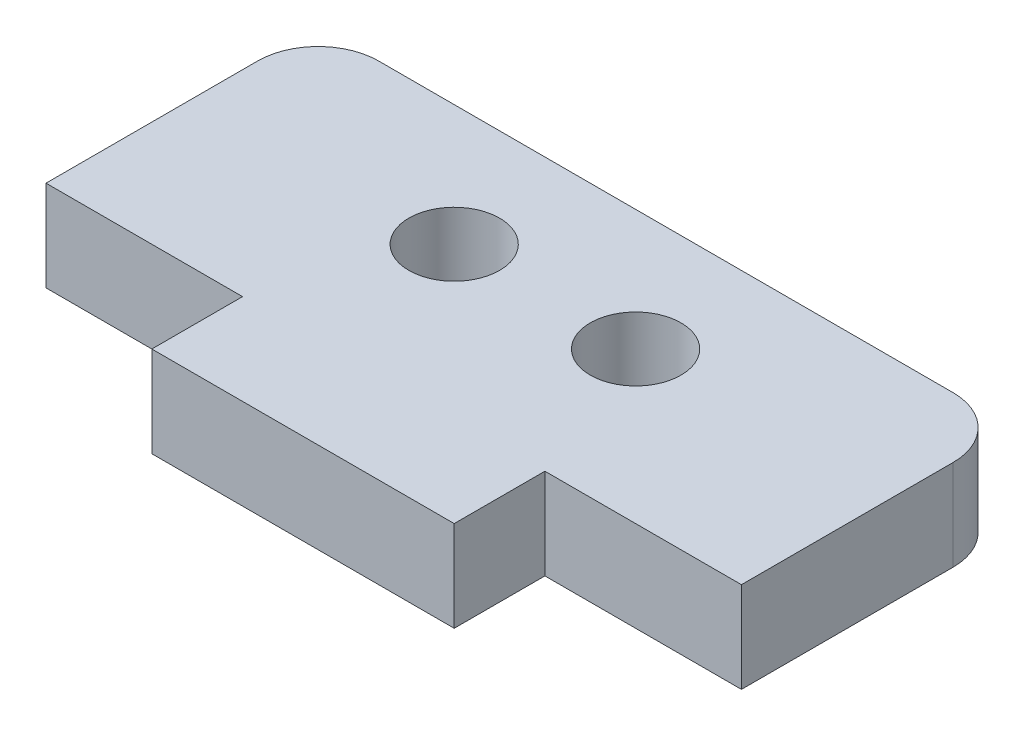
from build123d import *

# Parameters (mm, degrees)
SKETCH1_R           = 1.5
BOSS_EXTRUDE1_DEPTH = 3


with BuildPart() as part:
    # Sketch1 → Boss-Extrude1 (new body)
    with BuildSketch(Plane(origin=(0, 0, 0), x_dir=(1, 0, 0), z_dir=(0, 1, 0))):
        with BuildLine():
            Line((-11.129677419, 1.625806452), (7.870322581, 1.625806452))
            ThreePointArc((7.870322581, 1.625806452), (9.284536143, 1.040020014), (9.870322581, -0.374193548))
            Line((9.870322581, -0.374193548), (9.870322581, -7.374193548))
            Line((9.870322581, -7.374193548), (3.370322581, -7.374193548))
            Line((3.370322581, -7.374193548), (3.370322581, -10.374193548))
            Line((3.370322581, -10.374193548), (-6.629677419, -10.374193548))
            Line((-6.629677419, -10.374193548), (-6.629677419, -7.374193548))
            Line((-6.629677419, -7.374193548), (-13.129677419, -7.374193548))
            Line((-13.129677419, -7.374193548), (-13.129677419, -0.374193548))
            ThreePointArc((-13.129677419, -0.374193548), (-12.543890982, 1.040020014), (-11.129677419, 1.625806452))
        make_face()
        with Locations((-4.629677419, -2.374193548)):
            Circle(SKETCH1_R, mode=Mode.SUBTRACT)
        with Locations((1.370322581, -2.374193548)):
            Circle(SKETCH1_R, mode=Mode.SUBTRACT)
    extrude(amount=BOSS_EXTRUDE1_DEPTH)


solid = part.part
